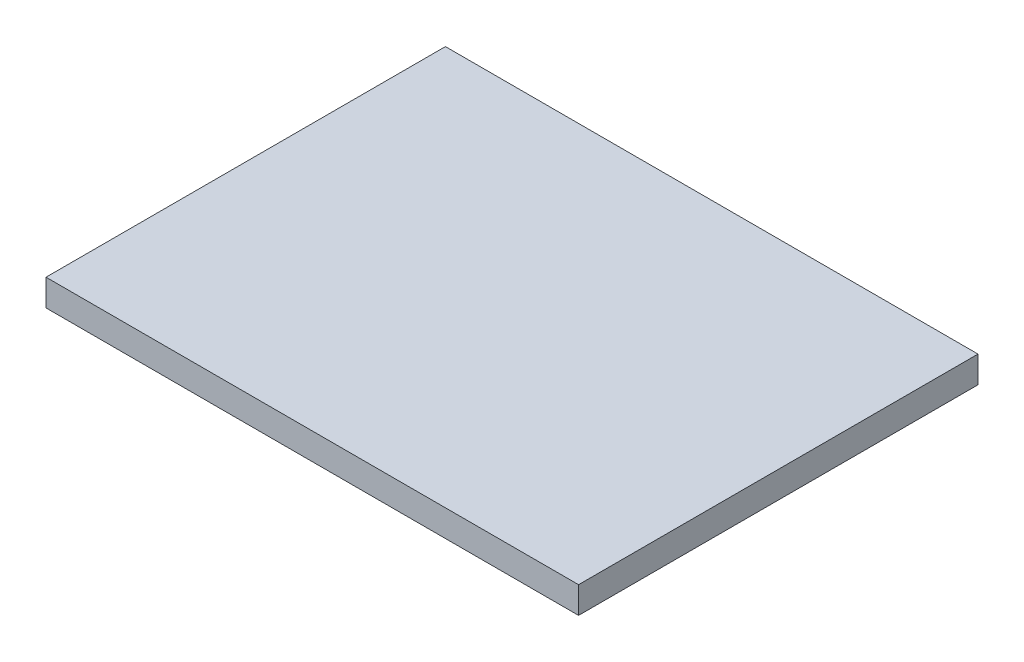
from build123d import *

# Parameters (mm, degrees)
SCHIZZO2_W                   = 200
SCHIZZO2_H                   = 150
ESTRUSIONE_ESTRUSIONE1_DEPTH = 10


with BuildPart() as part:
    # Schizzo2 → Estrusione-Estrusione1 (new body)
    with BuildSketch(Plane(origin=(0, 0, 0), x_dir=(1, 0, 0), z_dir=(0, 1, 0))):
        Rectangle(SCHIZZO2_W, SCHIZZO2_H)
    extrude(amount=ESTRUSIONE_ESTRUSIONE1_DEPTH)


solid = part.part
